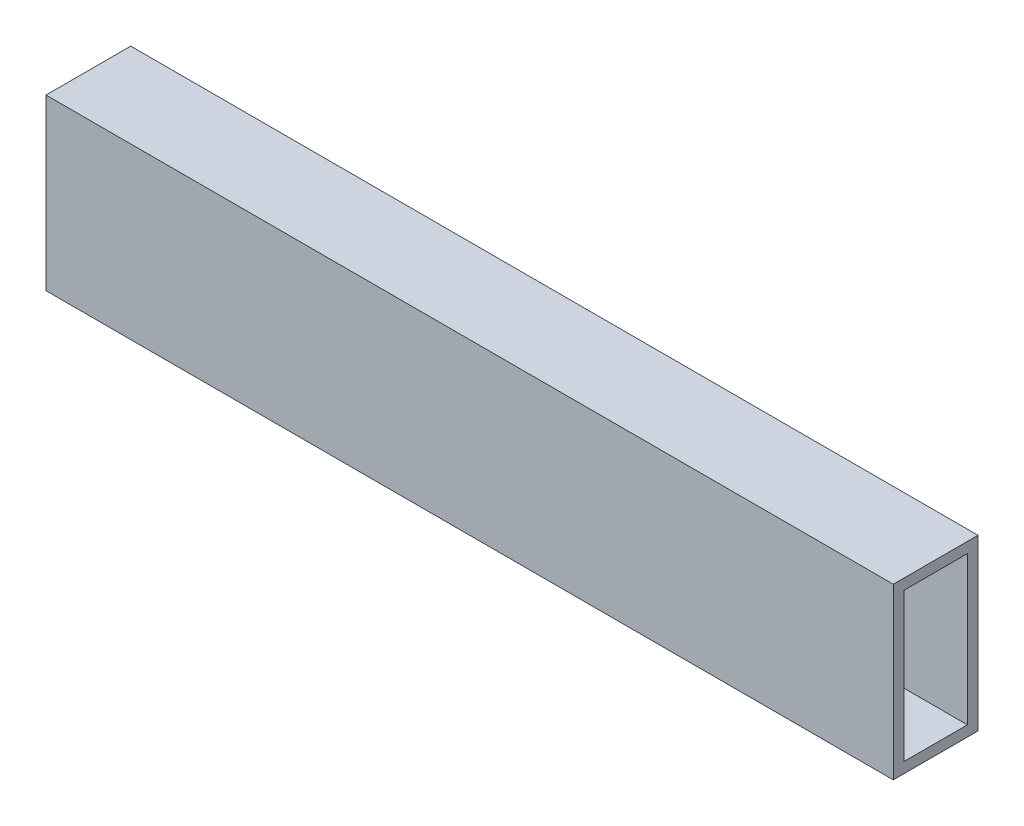
from build123d import *

# Parameters (mm, degrees)
SKETCH1_W           = 254
SKETCH1_H           = 25.4
BOSS_EXTRUDE1_DEPTH = 25.4
SHELL1_T            = -3.175


with BuildPart() as part:
    # Sketch1 → Boss-Extrude1 (new body, symmetric)
    with BuildSketch(Plane(origin=(0, 0, 0), x_dir=(1, 0, 0), z_dir=(0, 1, 0))):
        Rectangle(SKETCH1_W, SKETCH1_H)
    extrude(amount=BOSS_EXTRUDE1_DEPTH, both=True)

    # Shell1
    shell1_openings = [part.faces().sort_by_distance(p)[0] for p in [
        (-127, 0, 0),
        (127, 0, 0),
    ]]
    offset(amount=SHELL1_T, openings=shell1_openings, kind=Kind.INTERSECTION)


solid = part.part
